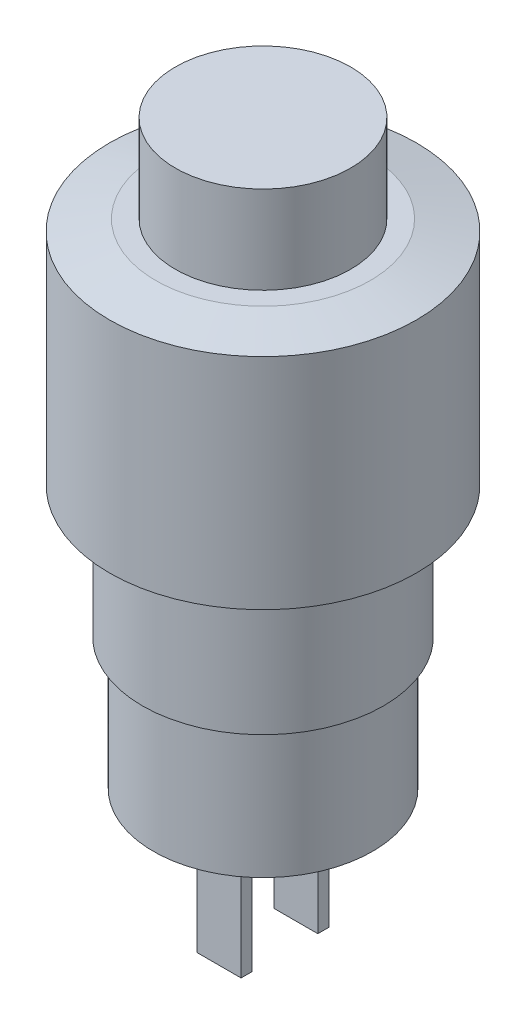
from build123d import *

# Parameters (mm, degrees)
ESBO_O2_W                = 2
ESBO_O2_H                = 0.5
RESSALTO_EXTRUS_O1_DEPTH = 6


with BuildPart() as part:
    # Esboço1 → Revolução1 (revolve)
    with BuildSketch(Plane.XY):
        Polygon((0, 26.5), (4, 26.5), (4, 22.5), (4.891304348, 22.5), (7, 22), (7, 12), (5.5, 12), (5.5, 6), (5, 6), (5, 0), (0, 0), align=None)
    revolve(axis=Axis((0, 0, 0), (0, 1, 0)))

    # Esboço2 → Ressalto-extrusão1 (add)
    with BuildSketch(Plane.XZ):
        with Locations((0, -1.75)):
            Rectangle(ESBO_O2_W, ESBO_O2_H)
        with Locations((0, 1.75)):
            Rectangle(ESBO_O2_W, ESBO_O2_H)
    extrude(amount=RESSALTO_EXTRUS_O1_DEPTH)


solid = part.part
